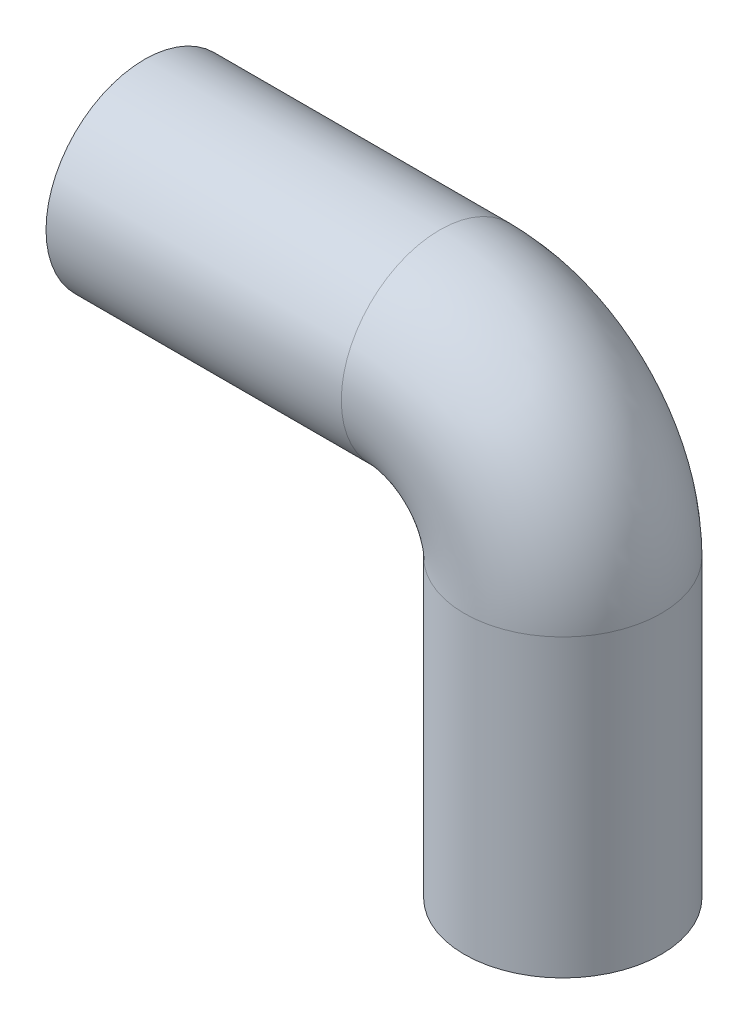
from build123d import *

# Parameters (mm, degrees)
SKETCH2_R = 50.8
SHELL2_T  = -2.54


with BuildPart() as part:
    # Sweep1: sweep along a path in Sketch1
    with BuildLine(Plane.XY) as sweep1_path:
        Line((0, 0), (0, 152.4))
        ThreePointArc((0, 152.4), (-18.598719395, 197.301280605), (-63.5, 215.9))
        Line((-63.5, 215.9), (-215.9, 215.9))
    # Sketch2 → Sweep1 (sweep)
    with BuildSketch(Plane(origin=(0, 0, 0), x_dir=(1, 0, 0), z_dir=(0, 1, 0))):
        Circle(SKETCH2_R)
    sweep(path=sweep1_path.line)

    # Shell2
    shell2_openings = [part.faces().sort_by_distance(p)[0] for p in [
        (-215.9, 215.9, 0),
        (0, 0, 0),
    ]]
    offset(amount=SHELL2_T, openings=shell2_openings, kind=Kind.INTERSECTION)


solid = part.part
